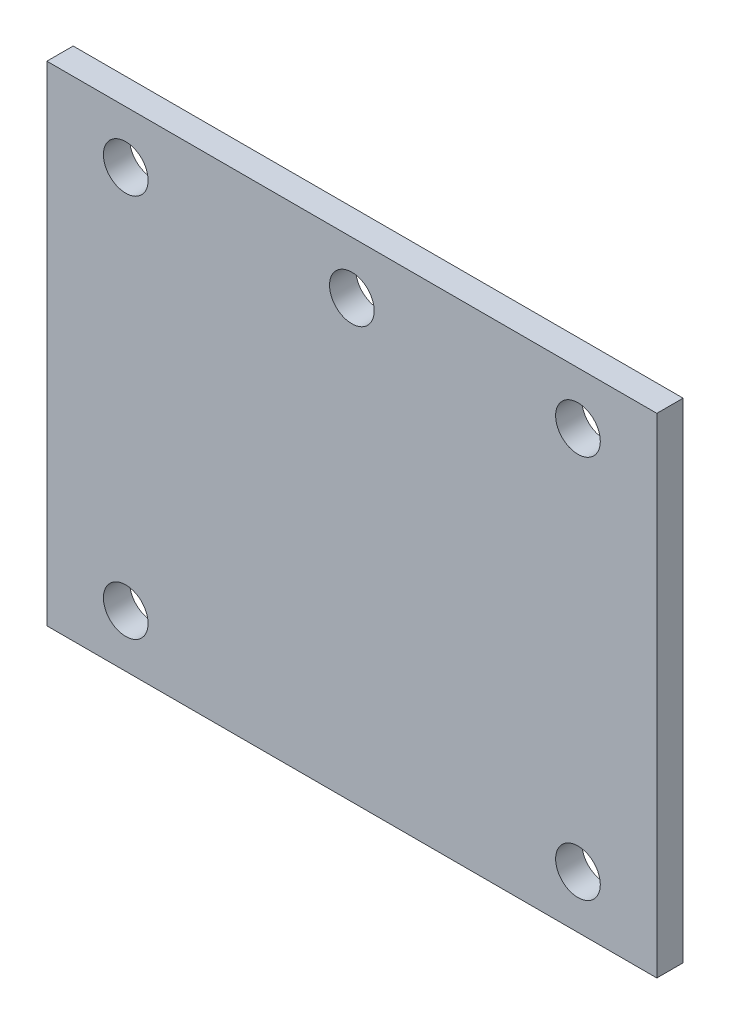
from build123d import *

# Parameters (mm, degrees)
SKETCH1_W           = 116
SKETCH1_H           = 93
SKETCH1_R           = 4.25
BOSS_EXTRUDE1_DEPTH = 5


with BuildPart() as part:
    # Sketch1 → Boss-Extrude1 (new body)
    with BuildSketch(Plane.XY):
        Rectangle(SKETCH1_W, SKETCH1_H)
        with Locations((-43, 36.5)):
            Circle(SKETCH1_R, mode=Mode.SUBTRACT)
        with Locations((43, 36.5)):
            Circle(SKETCH1_R, mode=Mode.SUBTRACT)
        with Locations((43, -36.5)):
            Circle(SKETCH1_R, mode=Mode.SUBTRACT)
        with Locations((-43, -36.5)):
            Circle(SKETCH1_R, mode=Mode.SUBTRACT)
        with Locations((0, 36.5)):
            Circle(SKETCH1_R, mode=Mode.SUBTRACT)
    extrude(amount=BOSS_EXTRUDE1_DEPTH)


solid = part.part
